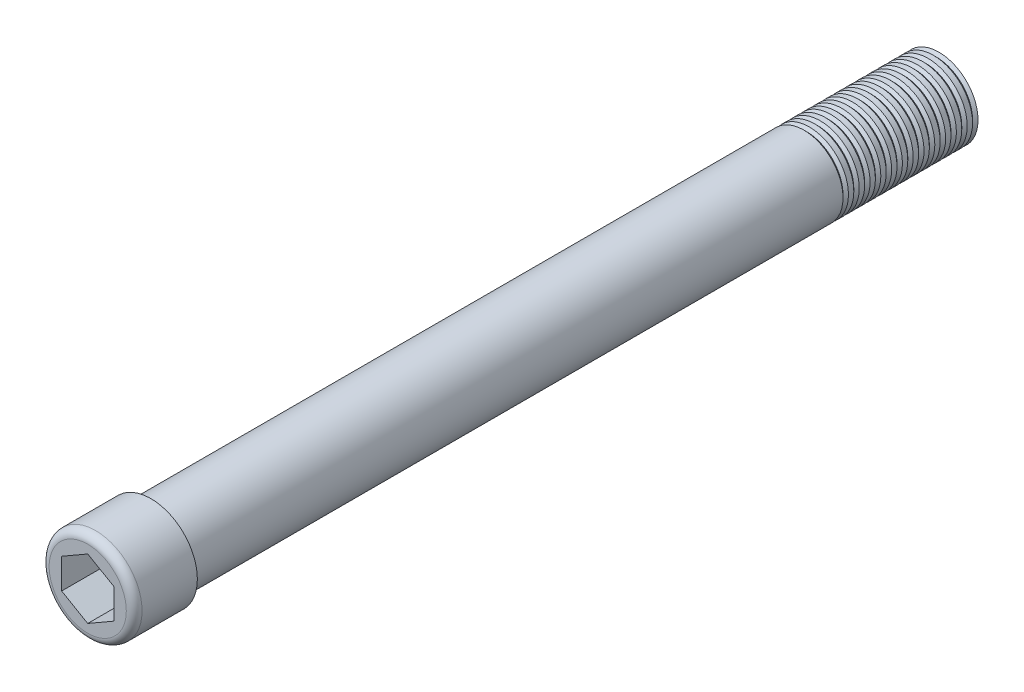
from build123d import *

# Parameters (mm, degrees)
SKETCH1_R          = 6.3
EXTRUDE1_DEPTH     = 127
SKETCH2_R          = 7.486213626
EXTRUDE2_DEPTH     = 10.18
FILLET1_R          = 1.27
CUT_EXTRUDE1_DEPTH = 10.18
LPATTERN1_COUNT    = 13
LPATTERN1_PITCH    = 1.74


with BuildPart() as part:
    # Sketch1 → Extrude1 (new body)
    with BuildSketch(Plane.XY):
        Circle(SKETCH1_R)
    extrude(amount=EXTRUDE1_DEPTH)

    # Sketch2 → Extrude2 (add)
    with BuildSketch(Plane.XY.offset(127)):
        Circle(SKETCH2_R)
    extrude(amount=EXTRUDE2_DEPTH)

    # Fillet1
    fillet1_edges = [part.edges().sort_by_distance(p)[0] for p in [
        (-7.486213626, 0, 137.18),
    ]]
    fillet(fillet1_edges, radius=FILLET1_R)

    # Sketch3 → Cut-Extrude1 (cut)
    with BuildSketch(Plane.XY.offset(137.18)):
        Polygon((4.202603037, 2.423907976), (0.002135635, 4.85151498), (-4.200467402, 2.427607004), (-4.202603037, -2.423907976), (-0.002135635, -4.85151498), (4.200467402, -2.427607004), align=None)
    extrude(amount=-CUT_EXTRUDE1_DEPTH, mode=Mode.SUBTRACT)

    # Sketch4 → Cut-Revolve1 (revolve, cut)
    with BuildSketch(Plane(origin=(0, 0, 0), x_dir=(1, 0, 0), z_dir=(0, 1, 0))):
        Polygon((-6.3, 0), (-5.861323423, -0.438676577), (-6.3, -0.877353155), (-6.738676577, -0.438676577), align=None)
    cut_revolve1 = revolve(axis=Axis((0, 0, 127), (0, 0, -1)), mode=Mode.SUBTRACT)

    # LPattern1: Cut-Revolve1 ×13
    with Locations(*[(0, 0, i * LPATTERN1_PITCH) for i in range(1, LPATTERN1_COUNT)]):
        add(cut_revolve1, mode=Mode.SUBTRACT)


solid = part.part
